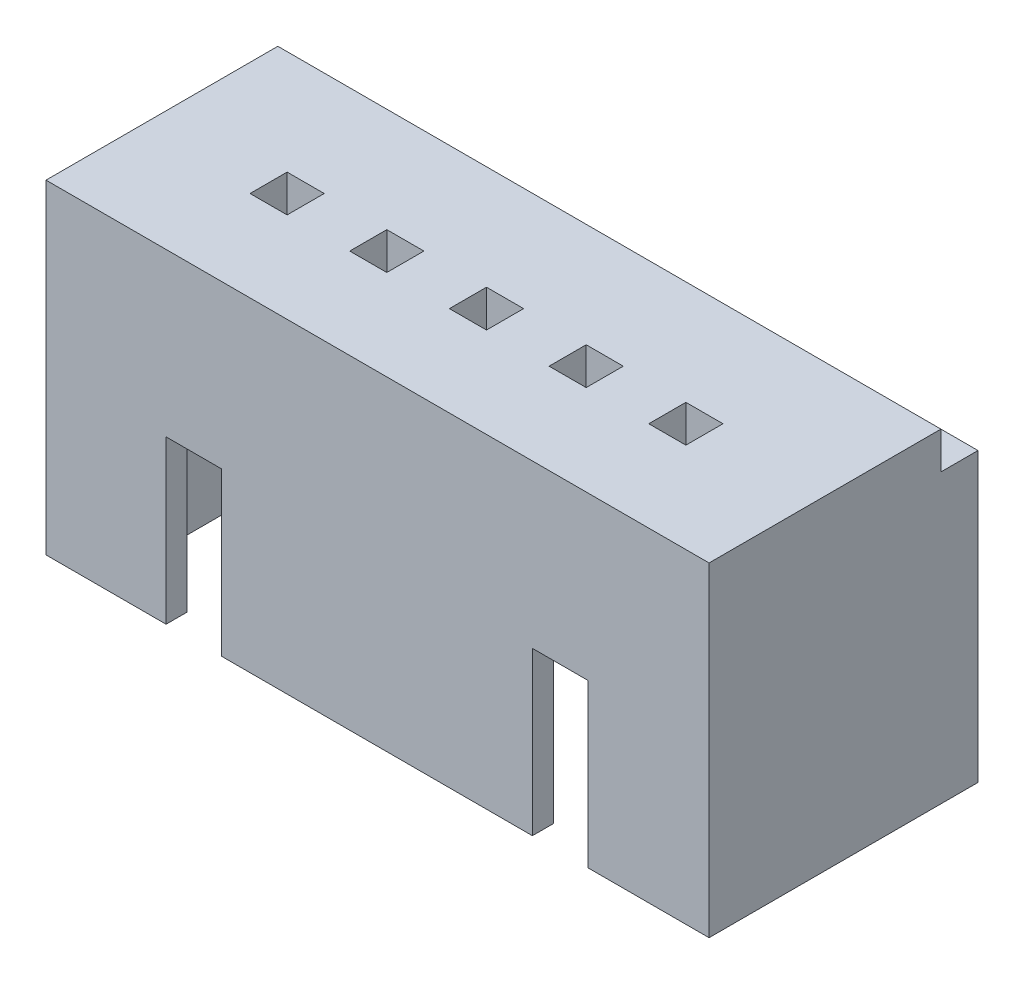
from build123d import *

# Parameters (mm, degrees)
SKETCH1_W           = 14.3
SKETCH1_H           = 5.8
BOSS_EXTRUDE1_DEPTH = 7
SKETCH3_W           = 12
SKETCH3_H           = 4.9
CUT_EXTRUDE1_DEPTH  = 5
SKETCH4_W           = 1.2
SKETCH4_H           = 3.5
CUT_EXTRUDE2_DEPTH  = 4
SKETCH5_W           = 14.3
SKETCH5_H           = 0.8
CUT_EXTRUDE3_DEPTH  = 0.8
SKETCH6_W           = 0.8
SKETCH6_H           = 0.8
CUT_EXTRUDE4_DEPTH  = 10
SKETCH7_W           = 12
SKETCH7_H           = 1
CUT_EXTRUDE5_DEPTH  = 0.3


with BuildPart() as part:
    # Sketch1 → Boss-Extrude1 (new body)
    with BuildSketch(Plane(origin=(0, 0, 0), x_dir=(1, 0, 0), z_dir=(0, 1, 0))):
        Rectangle(SKETCH1_W, SKETCH1_H)
    extrude(amount=BOSS_EXTRUDE1_DEPTH)

    # Sketch3 → Cut-Extrude1 (cut)
    with BuildSketch(Plane.XZ):
        Rectangle(SKETCH3_W, SKETCH3_H)
    extrude(amount=-CUT_EXTRUDE1_DEPTH, mode=Mode.SUBTRACT)

    # Sketch4 → Cut-Extrude2 (cut)
    with BuildSketch(Plane.XY.offset(2.9)):
        with Locations((-3.96, 1.75)):
            Rectangle(SKETCH4_W, SKETCH4_H)
        with Locations((3.94, 1.75)):
            Rectangle(SKETCH4_W, SKETCH4_H)
    extrude(amount=-CUT_EXTRUDE2_DEPTH, mode=Mode.SUBTRACT)

    # Sketch5 → Cut-Extrude3 (cut)
    with BuildSketch(Plane(origin=(0, 7, 0), x_dir=(1, 0, 0), z_dir=(0, 1, 0))):
        with Locations((0, 2.5)):
            Rectangle(SKETCH5_W, SKETCH5_H)
    extrude(amount=-CUT_EXTRUDE3_DEPTH, mode=Mode.SUBTRACT)

    # Sketch6 → Cut-Extrude4 (cut)
    with BuildSketch(Plane(origin=(0, 7, 0), x_dir=(1, 0, 0), z_dir=(0, 1, 0))):
        with Locations((4.3, -0.55)):
            Rectangle(SKETCH6_W, SKETCH6_H)
        with Locations((2.15, -0.55)):
            Rectangle(SKETCH6_W, SKETCH6_H)
        with Locations((0, -0.55)):
            Rectangle(SKETCH6_W, SKETCH6_H)
        with Locations((-2.15, -0.55)):
            Rectangle(SKETCH6_W, SKETCH6_H)
        with Locations((-4.3, -0.55)):
            Rectangle(SKETCH6_W, SKETCH6_H)
    extrude(amount=-CUT_EXTRUDE4_DEPTH, mode=Mode.SUBTRACT)

    # Sketch7 → Cut-Extrude5 (cut)
    with BuildSketch(Plane.XZ.offset(-5)):
        with Locations((0, -1.95)):
            Rectangle(SKETCH7_W, SKETCH7_H)
    extrude(amount=-CUT_EXTRUDE5_DEPTH, mode=Mode.SUBTRACT)


solid = part.part
